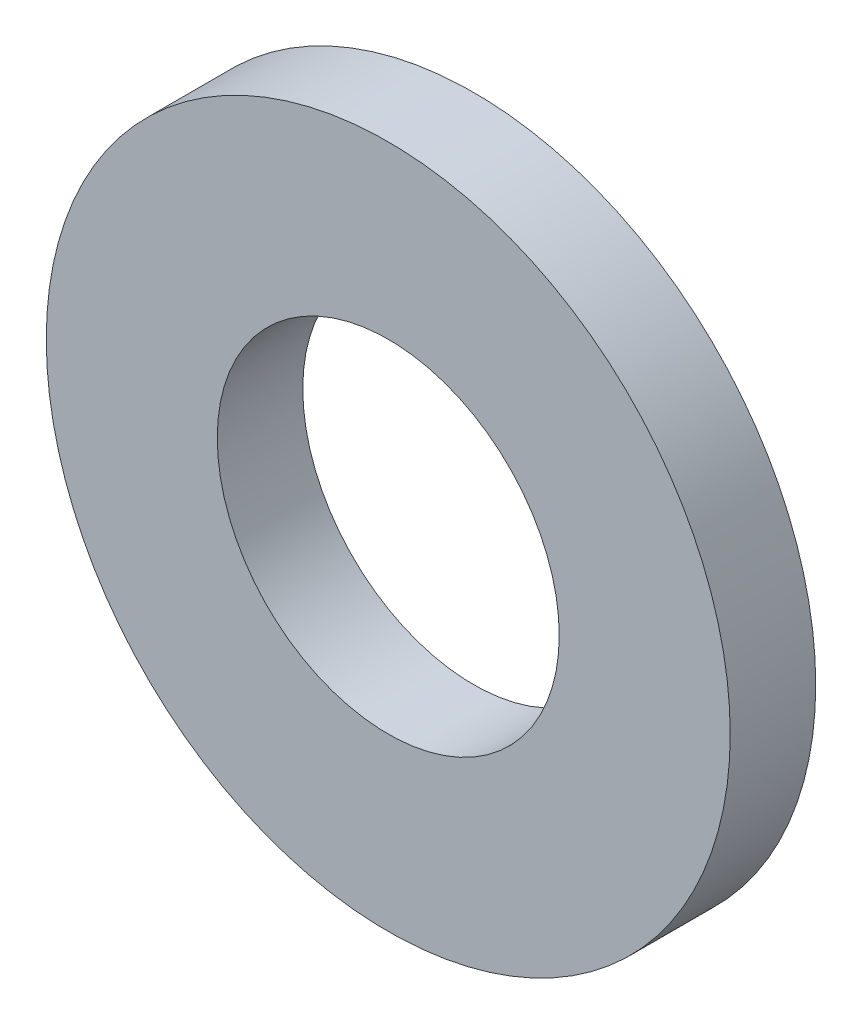
from build123d import *

# Parameters (mm, degrees)
SKETCH1_R           = 6.35
SKETCH1_R_2         = 3.175
BOSS_EXTRUDE1_DEPTH = 1.5875


with BuildPart() as part:
    # Sketch1 → Boss-Extrude1 (new body)
    with BuildSketch(Plane.XY):
        Circle(SKETCH1_R)
        Circle(SKETCH1_R_2, mode=Mode.SUBTRACT)
    extrude(amount=BOSS_EXTRUDE1_DEPTH)


solid = part.part
